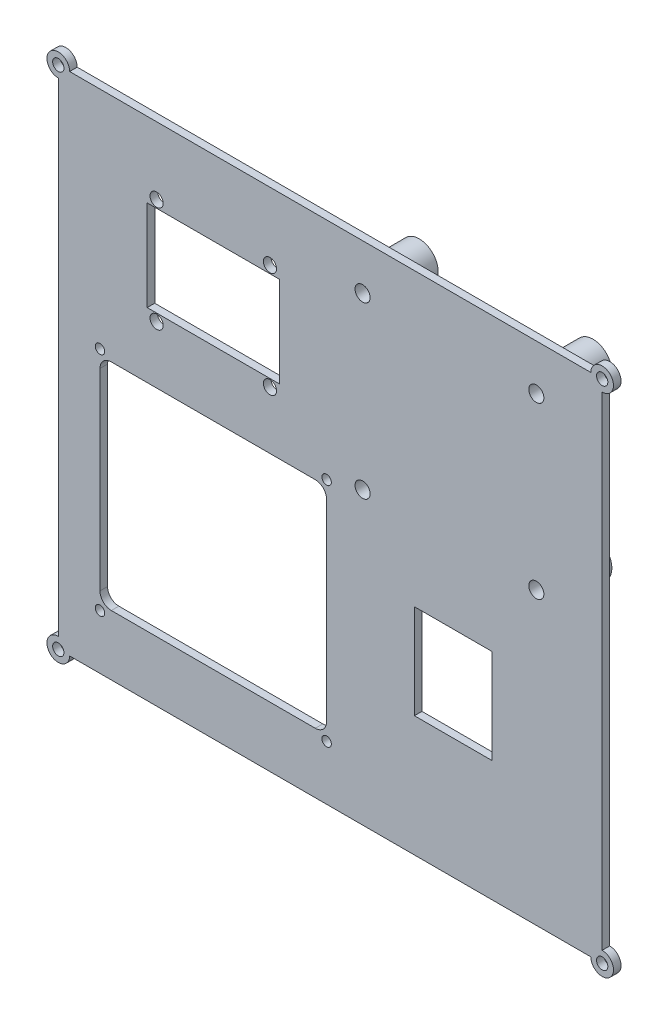
from build123d import *

# Parameters (mm, degrees)
BOSS_EXTRUDE1_DEPTH = 2
SKETCH2_R           = 1.5
CUT_EXTRUDE1_DEPTH  = 10
SKETCH3_R           = 1.25
SKETCH3_R_2         = 0.958506699
CUT_EXTRUDE2_DEPTH  = 10
CUT_EXTRUDE3_DEPTH  = 10
SKETCH5_R           = 0.958506699
CUT_EXTRUDE4_DEPTH  = 10
SKETCH8_R           = 2
CUT_EXTRUDE7_DEPTH  = 10
SKETCH9_R           = 5
SKETCH9_R_2         = 2
BOSS_EXTRUDE2_DEPTH = 15
SKETCH11_W          = 20.5
SKETCH11_H          = 25
CUT_EXTRUDE8_DEPTH  = 15
SKETCH12_R          = 1.75
SKETCH12_W          = 35
SKETCH12_H          = 24
CUT_EXTRUDE9_DEPTH  = 15


with BuildPart() as part:
    # Sketch1 → Boss-Extrude1 (new body)
    with BuildSketch(Plane.XY):
        with BuildLine():
            Line((119.800894358, -219.803615077), (119.800894358, -91.803615077))
            ThreePointArc((119.800894358, -91.803615077), (121.922214702, -86.682294733), (116.800894358, -88.803615077))
            Line((116.800894358, -88.803615077), (-21.199105642, -88.803615077))
            ThreePointArc((-21.199105642, -88.803615077), (-26.320425985, -86.682294733), (-24.199105642, -91.803615077))
            Line((-24.199105642, -91.803615077), (-24.199105642, -219.803615077))
            ThreePointArc((-24.199105642, -219.803615077), (-26.320425985, -224.92493542), (-21.199105642, -222.803615077))
            Line((-21.199105642, -222.803615077), (116.800894358, -222.803615077))
            ThreePointArc((116.800894358, -222.803615077), (121.922214702, -224.92493542), (119.800894358, -219.803615077))
        make_face()
    extrude(amount=BOSS_EXTRUDE1_DEPTH)

    # Sketch2 → Cut-Extrude1 (cut)
    with BuildSketch(Plane(origin=(0, 0, 0), x_dir=(-1, 0, 0), z_dir=(0, 0, -1))):
        with Locations((-119.800894358, -88.803615077)):
            Circle(SKETCH2_R)
        with Locations((24.199105642, -88.803615077)):
            Circle(SKETCH2_R)
        with Locations((24.199105642, -222.803615077)):
            Circle(SKETCH2_R)
        with Locations((-119.800894358, -222.803615077)):
            Circle(SKETCH2_R)
    extrude(amount=-CUT_EXTRUDE1_DEPTH, mode=Mode.SUBTRACT)

    # Sketch3 → Cut-Extrude2 (cut)
    with BuildSketch(Plane.XY.offset(2)):
        with Locations((-13.15761234, -148.369936061)):
            Circle(SKETCH3_R)
        with Locations((46.84238766, -148.369936061)):
            Circle(SKETCH3_R)
        with Locations((-13.15761234, -208.369936061)):
            Circle(SKETCH3_R)
        with Locations((46.84238766, -208.369936061)):
            Circle(SKETCH3_R)
        with Locations((46.84238766, -208.369936061)):
            Circle(SKETCH3_R_2, mode=Mode.SUBTRACT)
    extrude(amount=-CUT_EXTRUDE2_DEPTH, mode=Mode.SUBTRACT)

    # Sketch4 → Cut-Extrude3 (cut)
    with BuildSketch(Plane.XY.offset(2)):
        with BuildLine():
            Line((-10.15761234, -149.869936061), (43.84238766, -149.869936061))
            ThreePointArc((43.84238766, -149.869936061), (45.963708003, -150.748615717), (46.84238766, -152.869936061))
            Line((46.84238766, -152.869936061), (46.84238766, -203.869936061))
            ThreePointArc((46.84238766, -203.869936061), (45.963708003, -205.991256404), (43.84238766, -206.869936061))
            Line((43.84238766, -206.869936061), (-10.15761234, -206.869936061))
            ThreePointArc((-10.15761234, -206.869936061), (-12.278932684, -205.991256404), (-13.15761234, -203.869936061))
            Line((-13.15761234, -203.869936061), (-13.15761234, -152.869936061))
            ThreePointArc((-13.15761234, -152.869936061), (-12.278932684, -150.748615717), (-10.15761234, -149.869936061))
        make_face()
    extrude(amount=-CUT_EXTRUDE3_DEPTH, mode=Mode.SUBTRACT)

    # Sketch5 → Cut-Extrude4 (cut)
    with BuildSketch(Plane(origin=(0, 0, 0), x_dir=(-1, 0, 0), z_dir=(0, 0, -1))):
        with Locations((-46.84238766, -208.369936061)):
            Circle(SKETCH5_R)
    extrude(amount=-CUT_EXTRUDE4_DEPTH, mode=Mode.SUBTRACT)

    # Sketch8 → Cut-Extrude7 (cut)
    with BuildSketch(Plane(origin=(0, 0, 0), x_dir=(-1, 0, 0), z_dir=(0, 0, -1))):
        with Locations((-102.369057956, -100.884905857)):
            Circle(SKETCH8_R)
        with Locations((-56.369057956, -100.884905857)):
            Circle(SKETCH8_R)
        with Locations((-102.369057956, -145.884905857)):
            Circle(SKETCH8_R)
        with Locations((-56.369057956, -145.884905857)):
            Circle(SKETCH8_R)
    extrude(amount=-CUT_EXTRUDE7_DEPTH, mode=Mode.SUBTRACT)

    # Sketch9 → Boss-Extrude2 (add)
    with BuildSketch(Plane.XY.offset(2)):
        with Locations((56.369057956, -100.884905857)):
            Circle(SKETCH9_R)
        with Locations((56.369057956, -100.884905857)):
            Circle(SKETCH9_R_2, mode=Mode.SUBTRACT)
        with Locations((102.369057956, -100.884905857)):
            Circle(SKETCH9_R)
        with Locations((102.369057956, -100.884905857)):
            Circle(SKETCH9_R_2, mode=Mode.SUBTRACT)
        with Locations((102.369057956, -145.884905857)):
            Circle(SKETCH9_R)
        with Locations((102.369057956, -145.884905857)):
            Circle(SKETCH9_R_2, mode=Mode.SUBTRACT)
        with Locations((56.369057956, -145.884905857)):
            Circle(SKETCH9_R)
        with Locations((56.369057956, -145.884905857)):
            Circle(SKETCH9_R_2, mode=Mode.SUBTRACT)
    extrude(amount=-BOSS_EXTRUDE2_DEPTH)

    # Sketch11 → Cut-Extrude8 (cut)
    with BuildSketch(Plane.XY.offset(2)):
        with Locations((80.340901452, -178.369936061)):
            Rectangle(SKETCH11_W, SKETCH11_H)
    extrude(amount=-CUT_EXTRUDE8_DEPTH, mode=Mode.SUBTRACT)

    # Sketch12 → Cut-Extrude9 (cut)
    with BuildSketch(Plane.XY.offset(2)):
        with Locations((31.84238766, -106.65983664)):
            Circle(SKETCH12_R)
        with Locations((1.84238766, -106.65983664)):
            Circle(SKETCH12_R)
        with Locations((1.84238766, -134.65983664)):
            Circle(SKETCH12_R)
        with Locations((31.84238766, -134.65983664)):
            Circle(SKETCH12_R)
        with Locations((16.84238766, -120.65983664)):
            Rectangle(SKETCH12_W, SKETCH12_H)
    extrude(amount=-CUT_EXTRUDE9_DEPTH, mode=Mode.SUBTRACT)


solid = part.part
